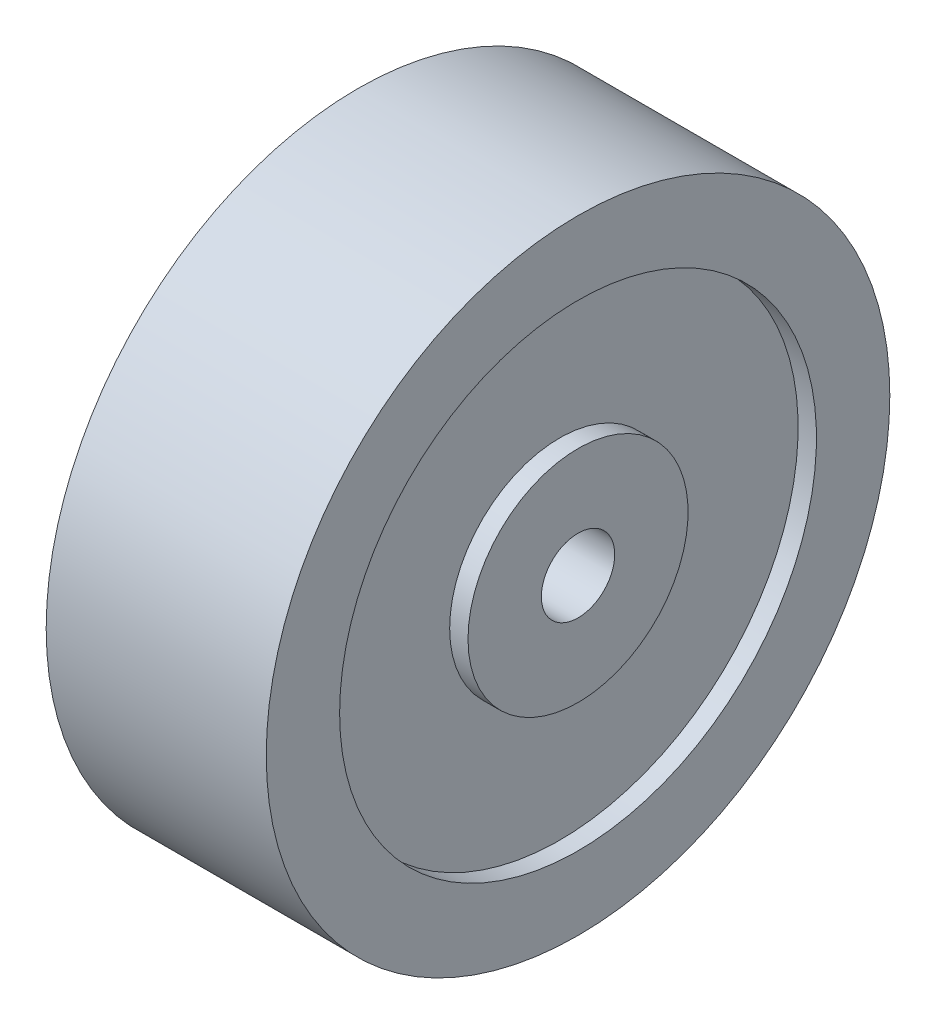
from build123d import *


with BuildPart() as part:
    # Croquis1 → Revolución2 (revolve)
    with BuildSketch(Plane.XY):
        Polygon((0, 6.35), (0, 19.05), (3.175, 19.05), (3.175, 41.275), (0, 41.275), (0, 53.975), (38.1, 53.975), (38.1, 41.275), (34.925, 41.275), (34.925, 19.05), (38.1, 19.05), (38.1, 6.35), align=None)
    revolve(axis=Axis((0, 0, 0), (1, 0, 0)))


solid = part.part
